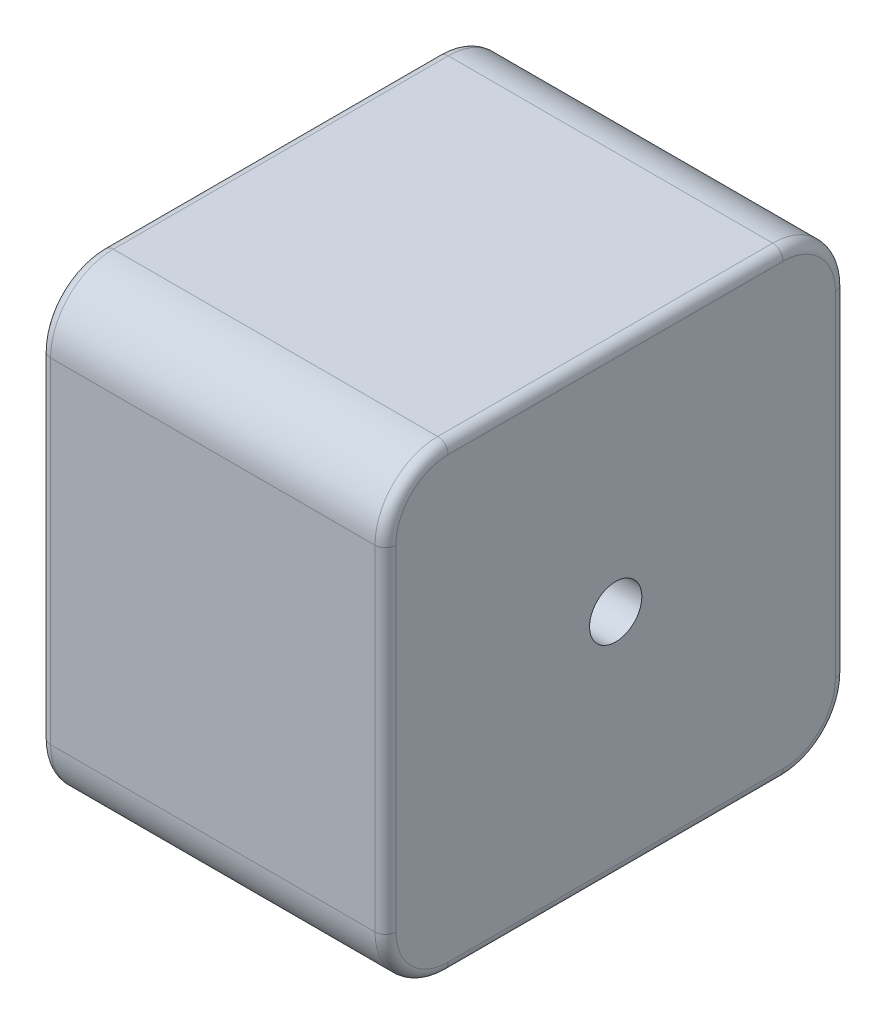
from build123d import *

# Parameters (mm, degrees)
SKETCH1_R           = 2.5
BOSS_EXTRUDE1_DEPTH = 33
FILLET1_R           = 1


with BuildPart() as part:
    # Sketch1 → Boss-Extrude1 (new body)
    with BuildSketch(Plane(origin=(0, 0, 0), x_dir=(0, 0, -1), z_dir=(1, 0, 0))):
        with BuildLine():
            Line((-16, 22), (16, 22))
            ThreePointArc((16, 22), (20.242640687, 20.242640687), (22, 16))
            Line((22, 16), (22, -16))
            ThreePointArc((22, -16), (20.242640687, -20.242640687), (16, -22))
            Line((16, -22), (-16, -22))
            ThreePointArc((-16, -22), (-20.242640687, -20.242640687), (-22, -16))
            Line((-22, -16), (-22, 16))
            ThreePointArc((-22, 16), (-20.242640687, 20.242640687), (-16, 22))
        make_face()
        Circle(SKETCH1_R, mode=Mode.SUBTRACT)
    extrude(amount=BOSS_EXTRUDE1_DEPTH)

    # Fillet1
    fillet1_edges = [part.edges().sort_by_distance(p)[0] for p in [
        (0, 0, -22),
        (0, -20.242640687, -20.242640687),
        (0, -22, 0),
        (0, -20.242640687, 20.242640687),
        (33, -20.242640687, -20.242640687),
        (33, 0, -22),
        (33, 20.242640687, -20.242640687),
        (33, 22, 0),
        (33, 20.242640687, 20.242640687),
        (33, 0, 22),
        (33, -20.242640687, 20.242640687),
        (0, 0, 22),
        (33, -22, 0),
        (0, 20.242640687, 20.242640687),
        (0, 22, 0),
        (0, 20.242640687, -20.242640687),
    ]]
    fillet(fillet1_edges, radius=FILLET1_R)


solid = part.part
